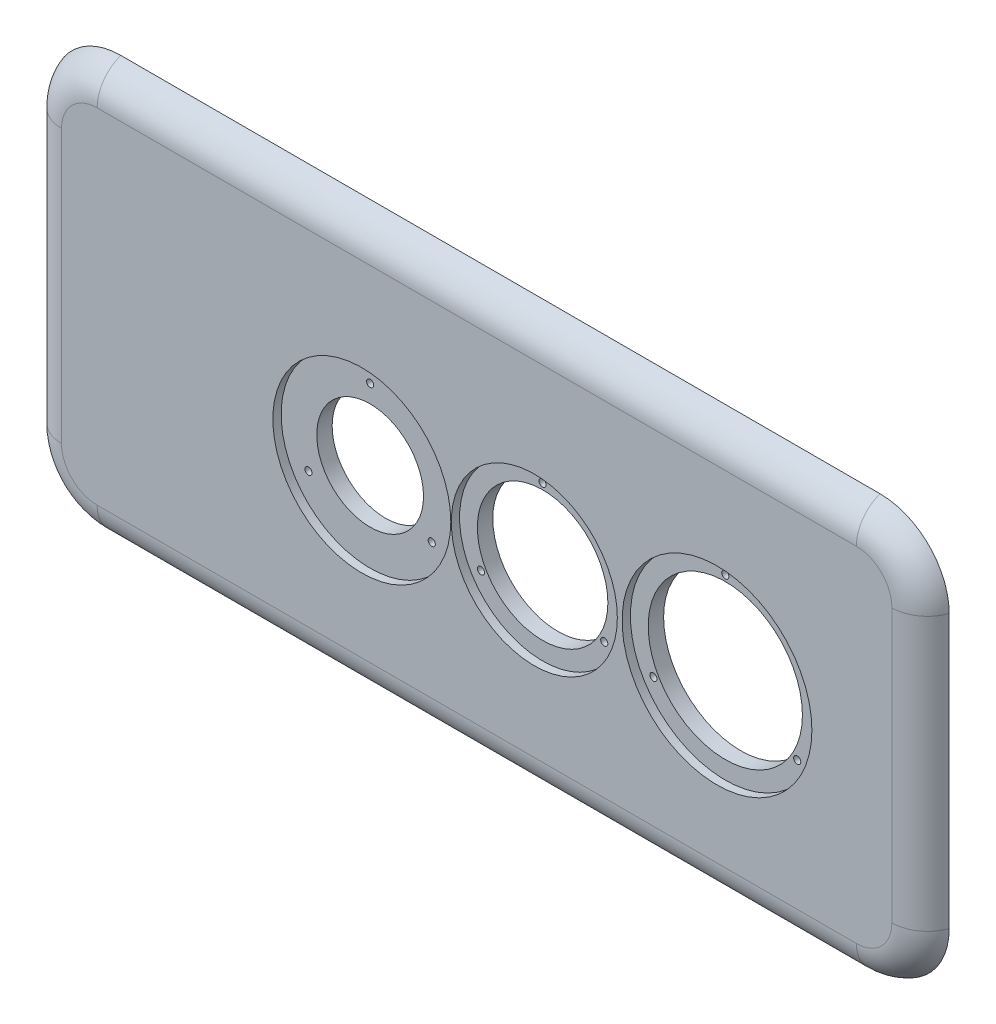
from build123d import *

# Parameters (mm, degrees)
SKETCH1_W           = 760
SKETCH1_H           = 350
BOSS_EXTRUDE1_DEPTH = 38
SKETCH2_R           = 65
SKETCH2_R_2         = 55
SKETCH2_R_3         = 45
CUT_EXTRUDE1_DEPTH  = 39
SKETCH4_R           = 75
CUT_EXTRUDE2_DEPTH  = 7
SKETCH5_R           = 70
CUT_EXTRUDE3_DEPTH  = 7
SKETCH12_R          = 3
CUT_EXTRUDE6_DEPTH  = 39
SKETCH15_OUTSIDE_W  = 929.516
SKETCH15_OUTSIDE_H  = 519.516
CUT_EXTRUDE7_DEPTH  = 39
FILLET1_R           = 30
SKETCH16_W          = 760
SKETCH16_H          = 350
CUT_EXTRUDE8_DEPTH  = 18
SKETCH17_R          = 80
SKETCH17_R_2        = 3
CUT_EXTRUDE9_DEPTH  = 7
SKETCH18_R          = 3
CUT_EXTRUDE10_DEPTH = 20


with BuildPart() as part:
    # Sketch1 → Boss-Extrude1 (new body)
    with BuildSketch(Plane.XY):
        with Locations((42.843137255, 32.696078431)):
            Rectangle(SKETCH1_W, SKETCH1_H)
    extrude(amount=BOSS_EXTRUDE1_DEPTH)

    # Sketch2 → Cut-Extrude1 (cut, through all)
    with BuildSketch(Plane.XY.offset(38)):
        with Locations((245.403137255, 24.656078431)):
            Circle(SKETCH2_R)
        with Locations((91.403137255, 24.656078431)):
            Circle(SKETCH2_R_2)
        with Locations((-54.006862745, 24.656078431)):
            Circle(SKETCH2_R_3)
    extrude(amount=-CUT_EXTRUDE1_DEPTH, mode=Mode.SUBTRACT)

    # Sketch4 → Cut-Extrude2 (cut)
    with BuildSketch(Plane.XY.offset(38)):
        with Locations((-54.006862745, 24.656078431)):
            Circle(SKETCH4_R)
    extrude(amount=-CUT_EXTRUDE2_DEPTH, mode=Mode.SUBTRACT)

    # Sketch5 → Cut-Extrude3 (cut)
    with BuildSketch(Plane.XY.offset(38)):
        with Locations((91.403137255, 24.656078431)):
            Circle(SKETCH5_R)
    extrude(amount=-CUT_EXTRUDE3_DEPTH, mode=Mode.SUBTRACT)

    # Sketch12 → Cut-Extrude6 (cut, through all)
    with BuildSketch(Plane.XY.offset(38)):
        with Locations((-54.006862745, 84.656078431)):
            Circle(SKETCH12_R)
        with Locations((-2.045338518, -5.343921569)):
            Circle(SKETCH12_R)
        with Locations((-105.968386972, -5.343921569)):
            Circle(SKETCH12_R)
        with Locations((91.403137255, 84.656078431)):
            Circle(SKETCH12_R)
        with Locations((143.364661482, -5.343921569)):
            Circle(SKETCH12_R)
        with Locations((39.441613028, -5.343921569)):
            Circle(SKETCH12_R)
    extrude(amount=-CUT_EXTRUDE6_DEPTH, mode=Mode.SUBTRACT)

    # Sketch15 outside → Cut-Extrude7 (cut, through all)
    with BuildSketch(Plane.XY.offset(38)):
        with Locations((42.843, 32.696)):
            Rectangle(SKETCH15_OUTSIDE_W, SKETCH15_OUTSIDE_H)
        with BuildLine():
            Line((-277.156862745, 207.696078431), (362.843137255, 207.696078431))
            ThreePointArc((362.843137255, 207.696078431), (405.269544126, 190.122485303), (422.843137255, 147.696078431))
            Line((422.843137255, 147.696078431), (422.843137255, -82.303921569))
            ThreePointArc((422.843137255, -82.303921569), (405.269544126, -124.73032844), (362.843137255, -142.303921569))
            Line((362.843137255, -142.303921569), (-277.156862745, -142.303921569))
            ThreePointArc((-277.156862745, -142.303921569), (-319.583269616, -124.73032844), (-337.156862745, -82.303921569))
            Line((-337.156862745, -82.303921569), (-337.156862745, 147.696078431))
            ThreePointArc((-337.156862745, 147.696078431), (-319.583269616, 190.122485303), (-277.156862745, 207.696078431))
        make_face(mode=Mode.SUBTRACT)
    extrude(amount=-CUT_EXTRUDE7_DEPTH, mode=Mode.SUBTRACT)

    # Fillet1
    fillet1_edges = [part.edges().sort_by_distance(p)[0] for p in [
        (-337.156862745, 32.696078431, 38),
        (42.843137255, -142.303921569, 38),
        (422.843137255, 32.696078431, 38),
        (42.843137255, 207.696078431, 38),
        (405.269544126, -124.73032844, 38),
        (-319.583269616, -124.73032844, 38),
        (-319.583269616, 190.122485303, 38),
        (405.269544126, 190.122485303, 38),
    ]]
    fillet(fillet1_edges, radius=FILLET1_R)

    # Sketch16 → Cut-Extrude8 (cut)
    with BuildSketch(Plane(origin=(0, 0, 0), x_dir=(-1, 0, 0), z_dir=(0, 0, -1))):
        with Locations((-42.843137255, 32.696078431)):
            Rectangle(SKETCH16_W, SKETCH16_H)
    extrude(amount=-CUT_EXTRUDE8_DEPTH, mode=Mode.SUBTRACT)

    # Sketch17 → Cut-Extrude9 (cut)
    with BuildSketch(Plane.XY.offset(38)):
        with Locations((245.403137255, 24.656078431)):
            Circle(SKETCH17_R)
        with Locations((245.403137255, 94.656078431)):
            Circle(SKETCH17_R_2, mode=Mode.SUBTRACT)
        with Locations((306.02491552, -10.343921569)):
            Circle(SKETCH17_R_2, mode=Mode.SUBTRACT)
        with Locations((184.78135899, -10.343921569)):
            Circle(SKETCH17_R_2, mode=Mode.SUBTRACT)
    extrude(amount=-CUT_EXTRUDE9_DEPTH, mode=Mode.SUBTRACT)

    # Sketch18 → Cut-Extrude10 (cut)
    with BuildSketch(Plane.XY.offset(38)):
        with Locations((245.403137255, 94.656078431)):
            Circle(SKETCH18_R)
        with Locations((184.78135899, -10.343921569)):
            Circle(SKETCH18_R)
        with Locations((306.02491552, -10.343921569)):
            Circle(SKETCH18_R)
    extrude(amount=-CUT_EXTRUDE10_DEPTH, mode=Mode.SUBTRACT)


solid = part.part
